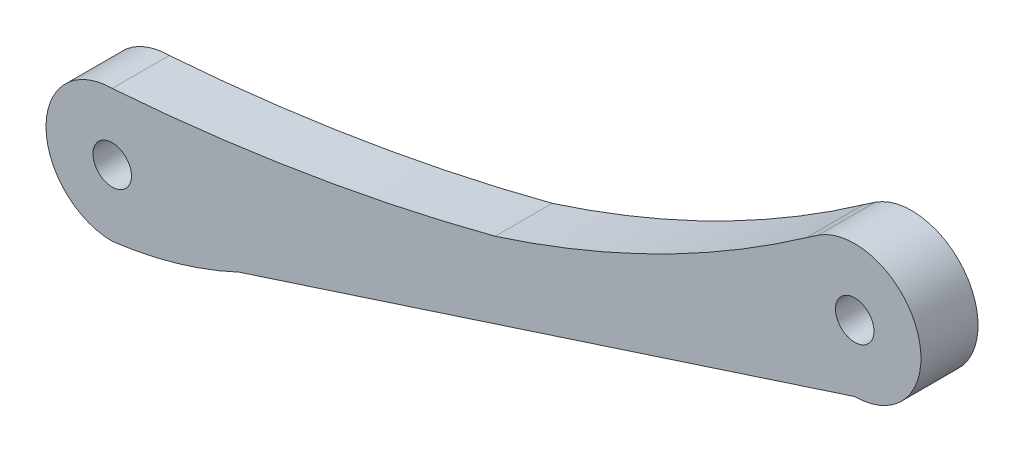
from build123d import *

# Parameters (mm, degrees)
SKETCH1_R           = 2.023987864
SKETCH1_R_2         = 2.023043511
BOSS_EXTRUDE1_DEPTH = 6


with BuildPart() as part:
    # Sketch1 → Boss-Extrude1 (new body)
    with BuildSketch(Plane.XY):
        with BuildLine():
            ThreePointArc((40.235925581, 13.621604134), (57.203735223, 20.491828906), (72.938383073, 29.847437358))
            Line((72.938383073, 29.847437358), (74.156447949, 30.67709719))
            ThreePointArc((74.156447949, 30.67709719), (84.681220688, 26.906078771), (78.020019153, 17.927224989))
            Line((78.020019153, 17.927224989), (13.323500668, -3.100956986))
            ThreePointArc((13.323500668, -3.100956986), (6.814395622, -5.556227345), (0, -6.956517793))
            ThreePointArc((0, -6.956517793), (-6.956517793, 0), (0, 6.956517793))
            ThreePointArc((0, 6.956517793), (20.269294729, 9.375497313), (40.235925581, 13.621604134))
        make_face()
        with Locations((78.020019153, 24.887546661)):
            Circle(SKETCH1_R, mode=Mode.SUBTRACT)
        Circle(SKETCH1_R_2, mode=Mode.SUBTRACT)
    extrude(amount=BOSS_EXTRUDE1_DEPTH)


with BuildPart() as part_1:
    # Body-Move/Copy1: moved
    add(part.part.moved(Location((0, 0, -6))))


solid = part_1.part
